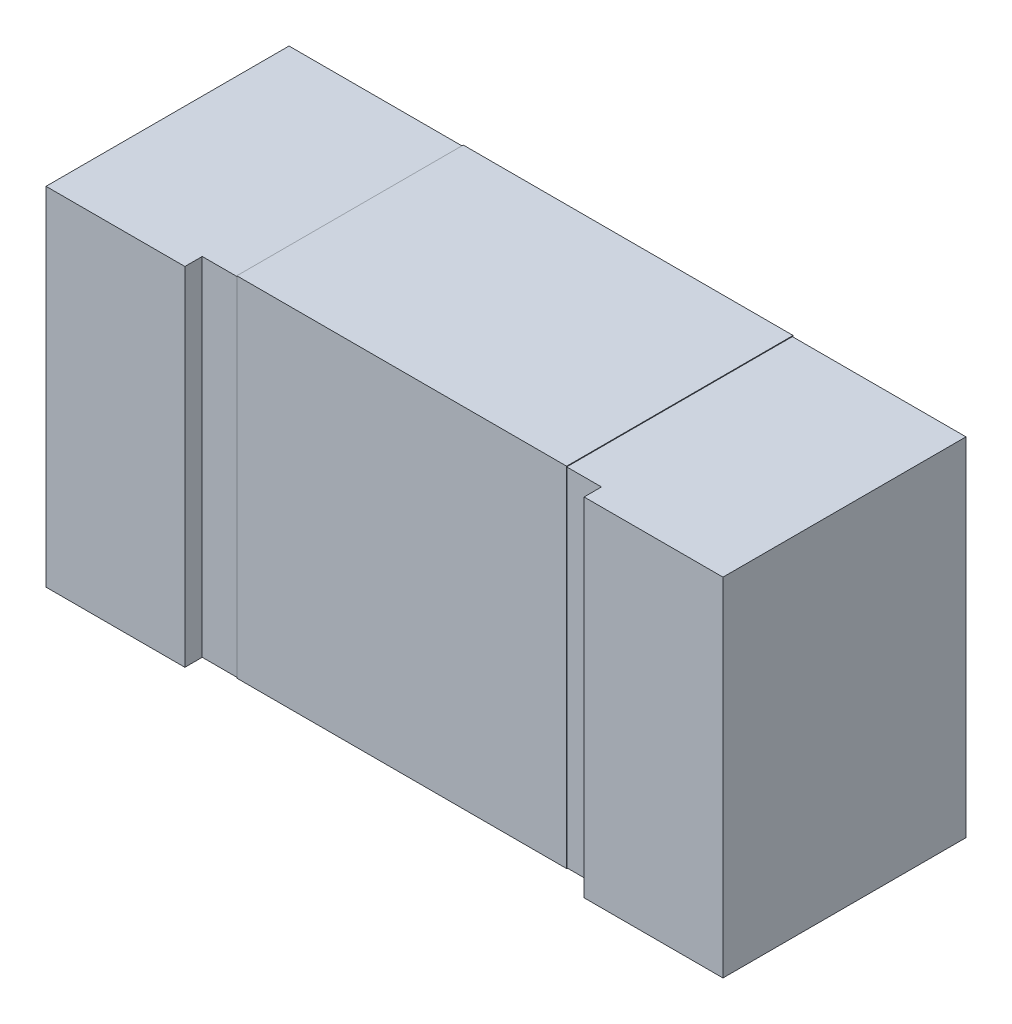
from build123d import *

# Parameters (mm, degrees)
BOSS_EXTRUDE1_DEPTH   = 0.254
BOSS_EXTRUDE1_2_DEPTH = 0.254
SKETCH3_W             = 0.9398
SKETCH3_H             = 0.3048
BOSS_EXTRUDE2_DEPTH   = 0.508
SKETCH4_W             = 0.331359425
SKETCH4_H             = 0.51
BOSS_EXTRUDE3_DEPTH   = 0.4826


with BuildPart() as part:
    # Sketch2 → Boss-Extrude1 (new body, symmetric)
    with BuildSketch(Plane(origin=(0, 0, 0), x_dir=(0, 0, -1), z_dir=(0, 1, 0))):
        Polygon((0, 0.2413), (-0.0254, 0.2413), (-0.0254, 0.4699), (-0.3302, 0.4699), (-0.3302, 0.2921), (-0.3556, 0.2921), (-0.3556, 0.4953), (0, 0.4953), align=None)
    extrude(amount=BOSS_EXTRUDE1_DEPTH, both=True)



with BuildPart() as body_2:
    # Sketch2 → Boss-Extrude1 2 (new body, symmetric)
    with BuildSketch(Plane(origin=(0, 0, 0), x_dir=(0, 0, -1), z_dir=(0, 1, 0))):
        Polygon((0, -0.4953), (0, -0.2413), (-0.0254, -0.2413), (-0.0254, -0.4699), (-0.3302, -0.4699), (-0.3302, -0.2921), (-0.3556, -0.2921), (-0.3556, -0.4953), align=None)
    extrude(amount=BOSS_EXTRUDE1_2_DEPTH, both=True)


with BuildPart() as part_1:
    add(part.part)

    add(body_2.part)  # Boss-Extrude2 merges body 2
    # Sketch3 → Boss-Extrude2 (add)
    with BuildSketch(Plane(origin=(0, 0.254, 0), x_dir=(1, 0, 0), z_dir=(0, 1, 0))):
        with Locations((0, -0.1778)):
            Rectangle(SKETCH3_W, SKETCH3_H)
    extrude(amount=-BOSS_EXTRUDE2_DEPTH)

    # Sketch4 → Boss-Extrude3 (add)
    with BuildSketch(Plane.ZY.offset(-0.2413)):
        with Locations((0.164679713, 0)):
            Rectangle(SKETCH4_W, SKETCH4_H)
    extrude(amount=BOSS_EXTRUDE3_DEPTH)


solid = part_1.part
